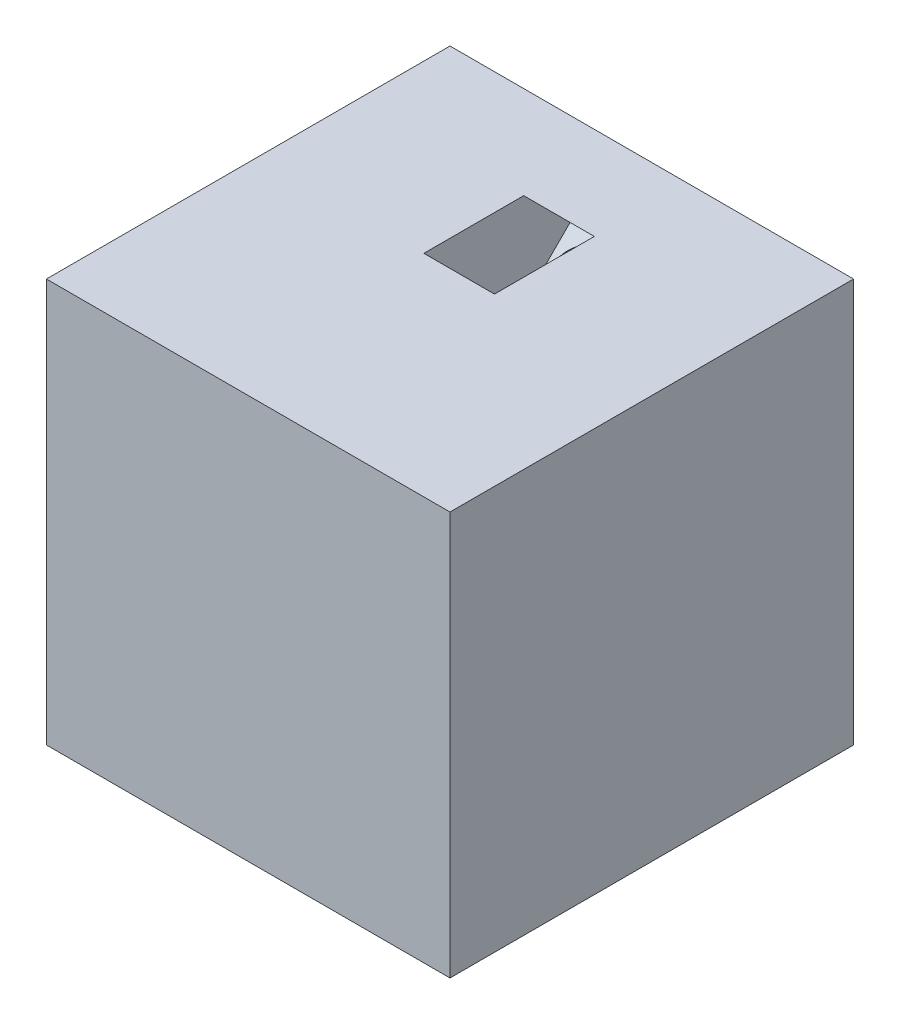
from build123d import *

# Parameters (mm, degrees)
ESQUISSE1_W                  = 40
ESQUISSE1_H                  = 40
BOSS_EXTRU_1_DEPTH           = 40
ESQUISSE2_R                  = 3
ENL_V_MAT_EXTRU_3_DEPTH      = 29.284271247
ENL_V_MAT_EXTRU_3_DEPTH_BACK = 29.284271247
ESQUISSE4_W                  = 7
ESQUISSE4_H                  = 7
ENL_V_MAT_EXTRU_5_DEPTH      = 23.5
ESQUISSE6_R                  = 3
ENL_V_MAT_EXTRU_6_DEPTH      = 29.284271247
ENL_V_MAT_EXTRU_6_DEPTH_BACK = 29.284271247
ESQUISSE7_W                  = 7
ESQUISSE7_H                  = 7
ENL_V_MAT_EXTRU_7_DEPTH      = 23.5


with BuildPart() as part:
    # Esquisse1 → Boss.-Extru.1 (new body)
    with BuildSketch(Plane.XY):
        with Locations((-101.164127838, 15.64516129)):
            Rectangle(ESQUISSE1_W, ESQUISSE1_H)
    extrude(amount=BOSS_EXTRU_1_DEPTH)

    # Esquisse2 → Enlèv. mat.-Extru.3 (cut, two sides)
    with BuildSketch(Plane(origin=(0, 17.822580645, 17.822580645), x_dir=(1, 0, 0), z_dir=(0, 0.707106781, 0.707106781))) as enl_v_mat_extru_3_sk:
        with Locations((-101.164127838, 15.204935265)):
            Circle(ESQUISSE2_R)
    extrude(amount=ENL_V_MAT_EXTRU_3_DEPTH, mode=Mode.SUBTRACT)
    extrude(enl_v_mat_extru_3_sk.sketch, amount=-ENL_V_MAT_EXTRU_3_DEPTH_BACK, mode=Mode.SUBTRACT)

    # Esquisse4 → Enlèv. mat.-Extru.5 (cut)
    with BuildSketch(Plane(origin=(0, 17.822580645, 17.822580645), x_dir=(1, 0, 0), z_dir=(0, 0.707106781, 0.707106781))):
        with Locations((-101.164127838, 15.204935265)):
            Rectangle(ESQUISSE4_W, ESQUISSE4_H)
    extrude(amount=ENL_V_MAT_EXTRU_5_DEPTH, mode=Mode.SUBTRACT)

    # Esquisse6 → Enlèv. mat.-Extru.6 (cut, two sides)
    with BuildSketch(Plane(origin=(-60.582063919, 0, 60.582063919), x_dir=(-0.707106781, 0, -0.707106781), z_dir=(0.707106781, 0, -0.707106781))) as enl_v_mat_extru_6_sk:
        with Locations((75.67597643, 5.64516129)):
            Circle(ESQUISSE6_R)
    extrude(amount=ENL_V_MAT_EXTRU_6_DEPTH, mode=Mode.SUBTRACT)
    extrude(enl_v_mat_extru_6_sk.sketch, amount=-ENL_V_MAT_EXTRU_6_DEPTH_BACK, mode=Mode.SUBTRACT)

    # Esquisse7 → Enlèv. mat.-Extru.7 (cut)
    with BuildSketch(Plane(origin=(-60.582063919, 0, 60.582063919), x_dir=(-0.707106781, 0, -0.707106781), z_dir=(0.707106781, 0, -0.707106781))):
        with Locations((75.67597643, 5.64516129)):
            Rectangle(ESQUISSE7_W, ESQUISSE7_H)
    extrude(amount=-ENL_V_MAT_EXTRU_7_DEPTH, mode=Mode.SUBTRACT)


solid = part.part
